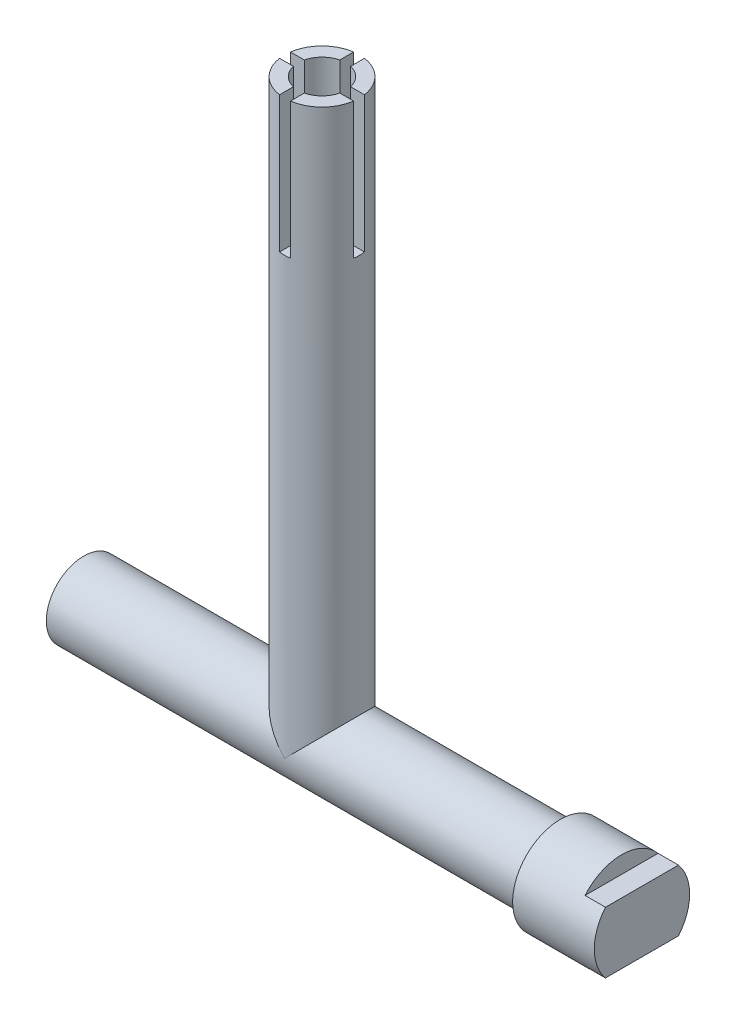
from build123d import *

# Parameters (mm, degrees)
SKETCH_1_R                  = 2.75
EXTRUDE_1_DEPTH             = 35
SKETCH_2_R                  = 2.75
EXTRUDE_2_DEPTH             = 42
HOLE_WIZARD_3_5_3_5_1_D     = 3.5
HOLE_WIZARD_3_5_3_5_1_DEPTH = 13
HOLE_WIZARD_3_5_3_5_1_TIP   = 1.051506083
SKETCH_4_W                  = 0.8
SKETCH_4_H                  = 0.8
CUT_EXTRUDE_1_DEPTH         = 10
SKETCH_5_R                  = 3.5
EXTRUDE_3_DEPTH             = 6
CUT_EXTRUDE_2_DEPTH         = 1.5
SKETCH_7_R                  = 2
CUT_EXTRUDE_3_DEPTH         = 7
M2_5X0_451_D                = 2.05
M2_5X0_451_DEPTH            = 6
M2_5X0_451_TIP              = 0.615882135


with BuildPart() as part:
    # Эскиз1 → Бобышка-Вытянуть1 (new body)
    with BuildSketch(Plane(origin=(0, 0, 0), x_dir=(0, 0, -1), z_dir=(1, 0, 0))):
        Circle(SKETCH_1_R)
    extrude(amount=EXTRUDE_1_DEPTH)

    # Эскиз2 → Бобышка-Вытянуть2 (add)
    with BuildSketch(Plane(origin=(0, 0, 0), x_dir=(1, 0, 0), z_dir=(0, 1, 0))):
        with Locations((17.5, 0)):
            Circle(SKETCH_2_R)
    extrude(amount=EXTRUDE_2_DEPTH)

    # Диаметр отверстия Ø3.5 (3.5)1
    with Locations(Plane(origin=(17.5, 42, 0), x_dir=(0, 0, 1), z_dir=(0, 1, 0))):
        with Locations((0, 0)):
            Hole(HOLE_WIZARD_3_5_3_5_1_D / 2, depth=HOLE_WIZARD_3_5_3_5_1_DEPTH)
            with Locations((0, 0, -(HOLE_WIZARD_3_5_3_5_1_DEPTH + HOLE_WIZARD_3_5_3_5_1_TIP / 2))):  # 118° drill point
                Cone(0, HOLE_WIZARD_3_5_3_5_1_D / 2, HOLE_WIZARD_3_5_3_5_1_TIP, mode=Mode.SUBTRACT)

    # Эскиз4 → Вырез-Вытянуть1 (cut)
    with BuildSketch(Plane(origin=(0, 42, 0), x_dir=(1, 0, 0), z_dir=(0, 1, 0))):
        with BuildLine():
            Line((17.1, 4), (17.1, 2.720753572))
            ThreePointArc((17.1, 2.720753572), (17.5, 2.75), (17.9, 2.720753572))
            Line((17.9, 2.720753572), (17.9, 4))
            Line((17.9, 4), (17.1, 4))
        make_face()
        with BuildLine():
            Line((17.1, -1.703672504), (17.1, -2.720753572))
            ThreePointArc((17.1, -2.720753572), (17.5, -2.75), (17.9, -2.720753572))
            Line((17.9, -2.720753572), (17.9, -1.703672504))
            ThreePointArc((17.9, -1.703672504), (17.5, -1.75), (17.1, -1.703672504))
        make_face()
        with BuildLine():
            ThreePointArc((17.9, 2.720753572), (17.5, 2.75), (17.1, 2.720753572))
            Line((17.1, 2.720753572), (17.1, 1.703672504))
            ThreePointArc((17.1, 1.703672504), (17.5, 1.75), (17.9, 1.703672504))
            Line((17.9, 1.703672504), (17.9, 2.720753572))
        make_face()
        with BuildLine():
            Line((17.1, 1.703672504), (17.1, 0.4))
            Line((17.1, 0.4), (17.9, 0.4))
            Line((17.9, 0.4), (17.9, 1.703672504))
            ThreePointArc((17.9, 1.703672504), (17.5, 1.75), (17.1, 1.703672504))
        make_face()
        with Locations((17.5, 0)):
            Rectangle(SKETCH_4_W, SKETCH_4_H)
        with BuildLine():
            Line((15.796327496, -0.4), (17.1, -0.4))
            Line((17.1, -0.4), (17.1, 0.4))
            Line((17.1, 0.4), (15.796327496, 0.4))
            ThreePointArc((15.796327496, 0.4), (15.75, 0), (15.796327496, -0.4))
        make_face()
        with BuildLine():
            ThreePointArc((14.779246428, 0.4), (14.75, 0), (14.779246428, -0.4))
            Line((14.779246428, -0.4), (15.796327496, -0.4))
            ThreePointArc((15.796327496, -0.4), (15.75, 0), (15.796327496, 0.4))
            Line((15.796327496, 0.4), (14.779246428, 0.4))
        make_face()
        with BuildLine():
            Line((19.203672504, -0.4), (20.220753572, -0.4))
            ThreePointArc((20.220753572, -0.4), (20.242678647, -0.200533883), (20.25, 0))
            ThreePointArc((20.25, 0), (20.242678647, 0.200533883), (20.220753572, 0.4))
            Line((20.220753572, 0.4), (19.203672504, 0.4))
            ThreePointArc((19.203672504, 0.4), (19.238379545, 0.20133693), (19.25, 0))
            ThreePointArc((19.25, 0), (19.238379545, -0.20133693), (19.203672504, -0.4))
        make_face()
        with BuildLine():
            Line((13.5, -0.4), (14.779246428, -0.4))
            ThreePointArc((14.779246428, -0.4), (14.75, 0), (14.779246428, 0.4))
            Line((14.779246428, 0.4), (13.5, 0.4))
            Line((13.5, 0.4), (13.5, -0.4))
        make_face()
        with BuildLine():
            Line((17.1, -0.4), (17.1, -1.703672504))
            ThreePointArc((17.1, -1.703672504), (17.5, -1.75), (17.9, -1.703672504))
            Line((17.9, -1.703672504), (17.9, -0.4))
            Line((17.9, -0.4), (17.1, -0.4))
        make_face()
        with BuildLine():
            Line((17.1, -2.720753572), (17.1, -4))
            Line((17.1, -4), (17.9, -4))
            Line((17.9, -4), (17.9, -2.720753572))
            ThreePointArc((17.9, -2.720753572), (17.5, -2.75), (17.1, -2.720753572))
        make_face()
        with BuildLine():
            Line((17.9, 0.4), (17.9, -0.4))
            Line((17.9, -0.4), (19.203672504, -0.4))
            ThreePointArc((19.203672504, -0.4), (19.238379545, -0.20133693), (19.25, 0))
            ThreePointArc((19.25, 0), (19.238379545, 0.20133693), (19.203672504, 0.4))
            Line((19.203672504, 0.4), (17.9, 0.4))
        make_face()
        with BuildLine():
            ThreePointArc((20.25, 0), (20.242678647, -0.200533883), (20.220753572, -0.4))
            Line((20.220753572, -0.4), (21.5, -0.4))
            Line((21.5, -0.4), (21.5, 0.4))
            Line((21.5, 0.4), (20.220753572, 0.4))
            ThreePointArc((20.220753572, 0.4), (20.242678647, 0.200533883), (20.25, 0))
        make_face()
    extrude(amount=-CUT_EXTRUDE_1_DEPTH, mode=Mode.SUBTRACT)

    # Эскиз5 → Бобышка-Вытянуть3 (add)
    with BuildSketch(Plane(origin=(35, 0, 0), x_dir=(0, 0, -1), z_dir=(1, 0, 0))):
        Circle(SKETCH_5_R)
    extrude(amount=EXTRUDE_3_DEPTH)

    # Эскиз6 → Вырез-Вытянуть2 (cut)
    with BuildSketch(Plane(origin=(41, 0, 0), x_dir=(0, 0, -1), z_dir=(1, 0, 0))):
        with BuildLine():
            ThreePointArc((2.680951324, 2.25), (0, 3.5), (-2.680951324, 2.25))
            Line((-2.680951324, 2.25), (2.680951324, 2.25))
        make_face()
        with BuildLine():
            Line((2.680951324, -2.25), (-2.680951324, -2.25))
            ThreePointArc((-2.680951324, -2.25), (0, -3.5), (2.680951324, -2.25))
        make_face()
    extrude(amount=-CUT_EXTRUDE_2_DEPTH, mode=Mode.SUBTRACT)

    # Эскиз7 → Вырез-Вытянуть3 (cut)
    with BuildSketch(Plane.ZY):
        Circle(SKETCH_7_R)
    extrude(amount=-CUT_EXTRUDE_3_DEPTH, mode=Mode.SUBTRACT)

    # Отверстие обработанное метчиком M2.5x0.451
    with Locations(Plane(origin=(7, 0, 0), x_dir=(0, 0, -1), z_dir=(-1, 0, 0))):
        with Locations((0, 0)):
            Hole(M2_5X0_451_D / 2, depth=M2_5X0_451_DEPTH)
            with Locations((0, 0, -(M2_5X0_451_DEPTH + M2_5X0_451_TIP / 2))):  # 118° drill point
                Cone(0, M2_5X0_451_D / 2, M2_5X0_451_TIP, mode=Mode.SUBTRACT)


solid = part.part
